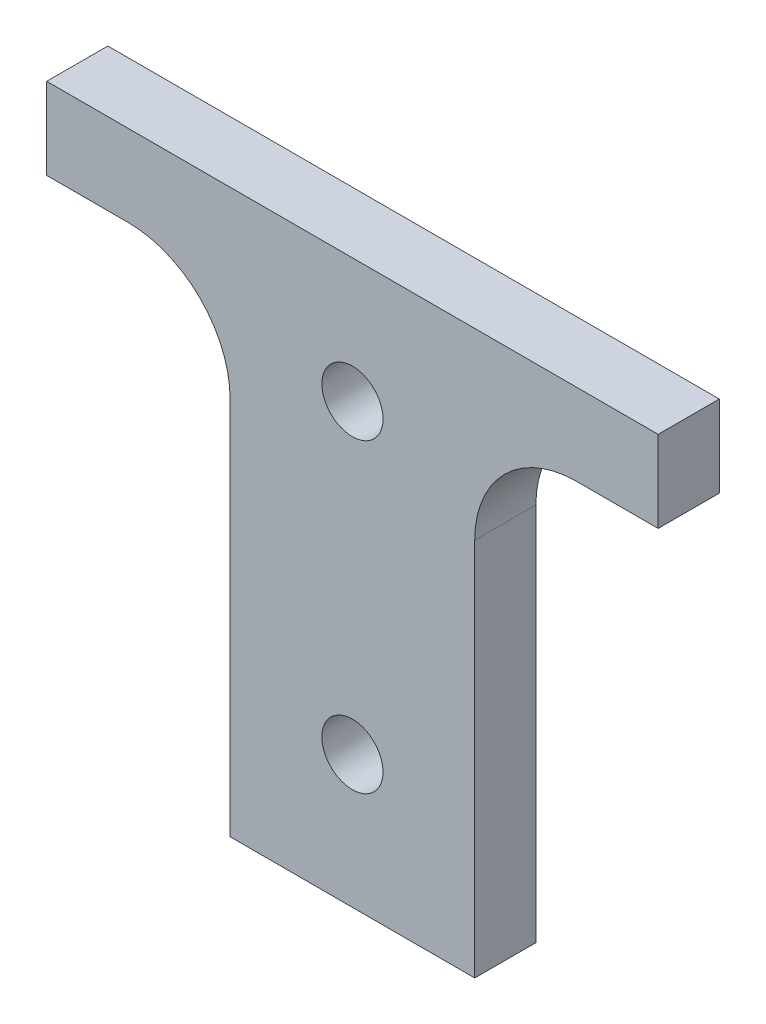
from build123d import *

# Parameters (mm, degrees)
SKETCH1_R           = 1.5
BOSS_EXTRUDE1_DEPTH = 3
FILLET1_R           = 5
FILLET2_R           = 5


with BuildPart() as part:
    # Sketch1 → Boss-Extrude1 (new body)
    with BuildSketch(Plane.XY):
        Polygon((6, 0), (-6, 0), (-6, 23.6), (-15, 23.6), (-15, 27.6), (15, 27.6), (15, 23.6), (6, 23.6), align=None)
        with Locations((0, 6.5)):
            Circle(SKETCH1_R, mode=Mode.SUBTRACT)
        with Locations((0, 21.5)):
            Circle(SKETCH1_R, mode=Mode.SUBTRACT)
    extrude(amount=BOSS_EXTRUDE1_DEPTH)

    # Fillet1
    fillet1_edges = [part.edges().sort_by_distance(p)[0] for p in [
        (-6, 23.6, 1.5),
    ]]
    fillet(fillet1_edges, radius=FILLET1_R)

    # Fillet2
    fillet2_edges = [part.edges().sort_by_distance(p)[0] for p in [
        (6, 23.6, 1.5),
    ]]
    fillet(fillet2_edges, radius=FILLET2_R)


solid = part.part
